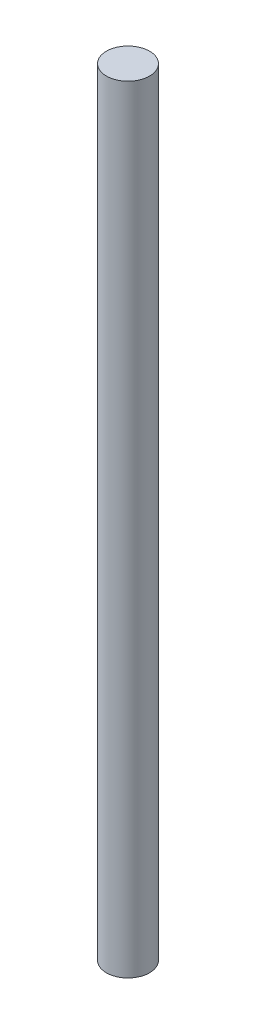
from build123d import *

# Parameters (mm, degrees)
SKETCH1_R           = 2.5
BOSS_EXTRUDE1_DEPTH = 90


with BuildPart() as part:
    # Sketch1 → Boss-Extrude1 (new body)
    with BuildSketch(Plane(origin=(0, 0, 0), x_dir=(1, 0, 0), z_dir=(0, 1, 0))):
        Circle(SKETCH1_R)
    extrude(amount=BOSS_EXTRUDE1_DEPTH)


solid = part.part
